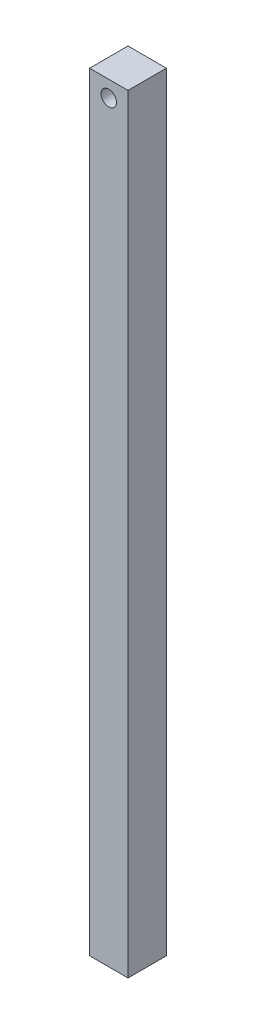
from build123d import *

# Parameters (mm, degrees)
SKETCH1_W           = 5
SKETCH1_H           = 100
BOSS_EXTRUDE1_DEPTH = 5
SKETCH3_R           = 1
CUT_EXTRUDE2_DEPTH  = 6


with BuildPart() as part:
    # Sketch1 → Boss-Extrude1 (new body)
    with BuildSketch(Plane.XY):
        Rectangle(SKETCH1_W, SKETCH1_H)
    extrude(amount=BOSS_EXTRUDE1_DEPTH)

    # Sketch3 → Cut-Extrude2 (cut, through all)
    with BuildSketch(Plane.XY.offset(5)):
        with Locations((0, 47.884965779)):
            Circle(SKETCH3_R)
    extrude(amount=-CUT_EXTRUDE2_DEPTH, mode=Mode.SUBTRACT)


solid = part.part
